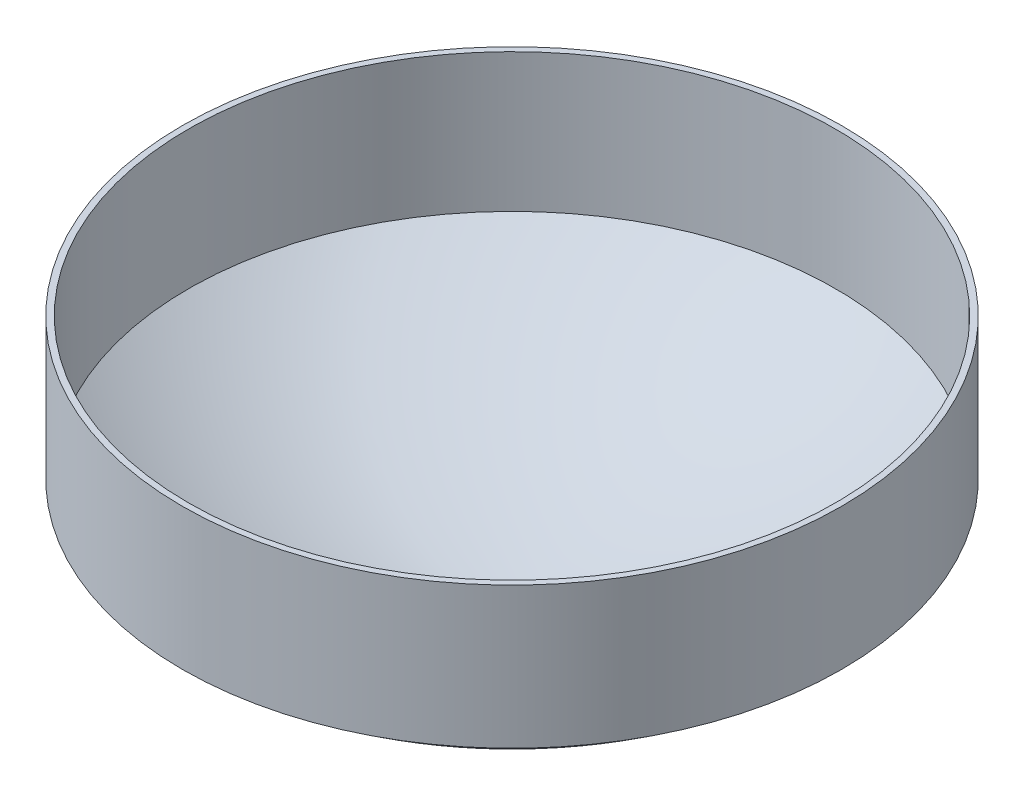
from build123d import *

# Parameters (mm, degrees)
SKETCH1_R           = 177.8
SKETCH1_R_2         = 174.5488
BOSS_EXTRUDE1_DEPTH = 76.2


with BuildPart() as part:
    # Sketch1 → Boss-Extrude1 (new body)
    with BuildSketch(Plane(origin=(0, 0, 0), x_dir=(1, 0, 0), z_dir=(0, 1, 0))):
        Circle(SKETCH1_R)
        Circle(SKETCH1_R_2, mode=Mode.SUBTRACT)
    extrude(amount=BOSS_EXTRUDE1_DEPTH)

    # Sketch2 → Revolve1 (revolve)
    with BuildSketch(Plane(origin=(0, 0, 0), x_dir=(0, 0, -1), z_dir=(1, 0, 0))):
        with BuildLine():
            Line((15.1765, -67.31), (15.1765, -64.033454417))
            ThreePointArc((15.1765, -64.033454417), (99.978812863, -41.559151242), (175.804024592, 2.566395061))
            Line((175.804024592, 2.566395061), (177.8, 0))
            ThreePointArc((177.8, 0), (101.035221552, -44.640654854), (15.1765, -67.31))
        make_face()
    revolve(axis=Axis((0, 76.2, 0), (0, -1, 0)))


solid = part.part
